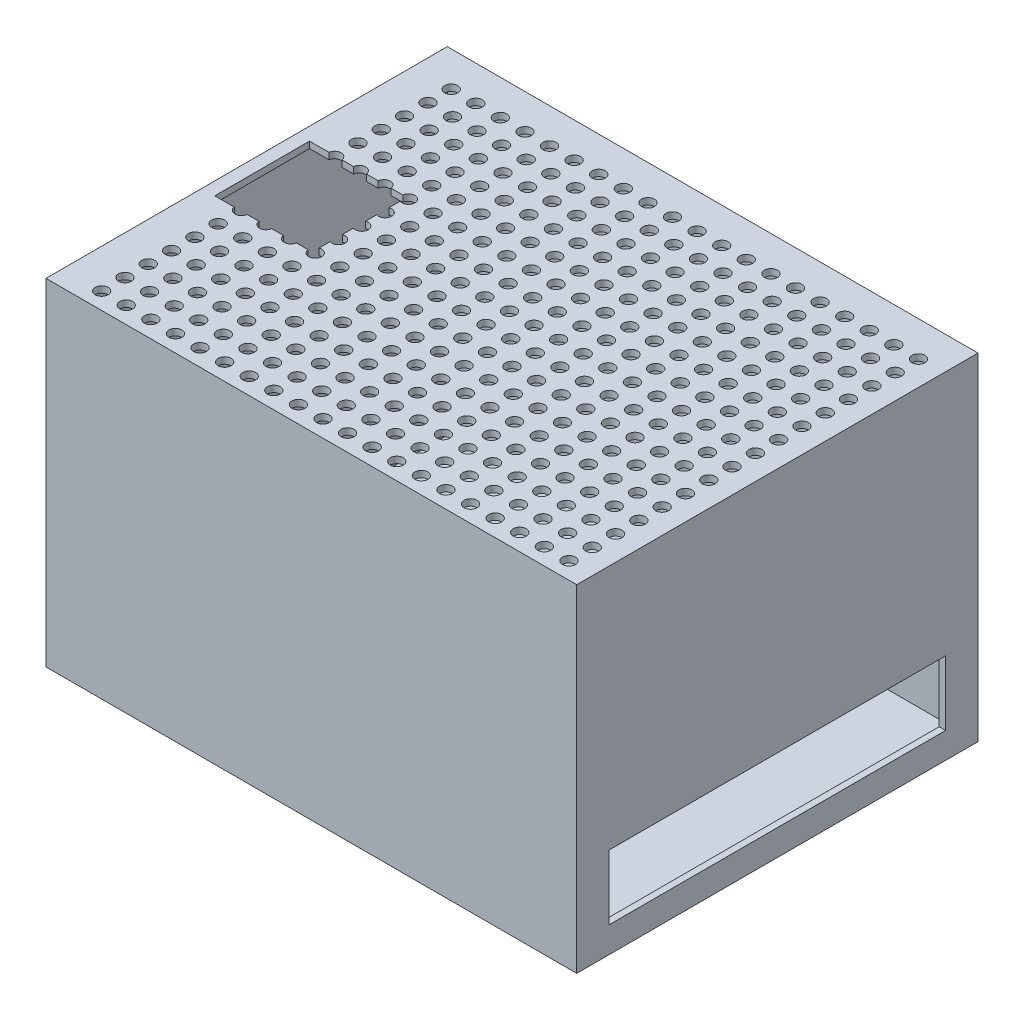
from build123d import *

# Parameters (mm, degrees)
SKETCH1_W           = 410
SKETCH1_H           = 260
SKETCH1_W_2         = 400
SKETCH1_H_2         = 250
BOSS_EXTRUDE1_DEPTH = 300
SKETCH2_W           = 410
SKETCH2_H           = 260
BOSS_EXTRUDE2_DEPTH = 5
SKETCH3_W           = 410
SKETCH3_H           = 260
BOSS_EXTRUDE3_DEPTH = 5
SKETCH4_R           = 5
CUT_EXTRUDE1_DEPTH  = 10
LPATTERN1_COUNT     = 16
LPATTERN1_PITCH     = 18
SKETCH5_W           = 75.209999999
SKETCH5_H           = 73.21
CUT_EXTRUDE2_DEPTH  = 10
SKETCH8_W           = 260
SKETCH8_H           = 50
CUT_EXTRUDE3_DEPTH  = 10


with BuildPart() as part:
    # Sketch1 → Boss-Extrude1 (new body)
    with BuildSketch(Plane.XY):
        with Locations((200, 125)):
            Rectangle(SKETCH1_W, SKETCH1_H)
        with Locations((200, 125)):
            Rectangle(SKETCH1_W_2, SKETCH1_H_2, mode=Mode.SUBTRACT)
    extrude(amount=BOSS_EXTRUDE1_DEPTH)

    # Sketch2 → Boss-Extrude2 (add)
    with BuildSketch(Plane.XY.offset(300)):
        with Locations((200, 125)):
            Rectangle(SKETCH2_W, SKETCH2_H)
    extrude(amount=BOSS_EXTRUDE2_DEPTH)

    # Sketch3 → Boss-Extrude3 (add)
    with BuildSketch(Plane(origin=(0, 0, 0), x_dir=(-1, 0, 0), z_dir=(0, 0, -1))):
        with Locations((-200, 125)):
            Rectangle(SKETCH3_W, SKETCH3_H)
    extrude(amount=BOSS_EXTRUDE3_DEPTH)

    # Sketch4 → Cut-Extrude1 (cut)
    with BuildSketch(Plane(origin=(0, 255, 0), x_dir=(1, 0, 0), z_dir=(0, 1, 0))):
        with Locations((25, -22)):
            Circle(SKETCH4_R)
        with Locations((44, -22)):
            Circle(SKETCH4_R)
        with Locations((63, -22)):
            Circle(SKETCH4_R)
        with Locations((82, -22)):
            Circle(SKETCH4_R)
        with Locations((101, -22)):
            Circle(SKETCH4_R)
        with Locations((120, -22)):
            Circle(SKETCH4_R)
        with Locations((139, -22)):
            Circle(SKETCH4_R)
        with Locations((158, -22)):
            Circle(SKETCH4_R)
        with Locations((177, -22)):
            Circle(SKETCH4_R)
        with Locations((196, -22)):
            Circle(SKETCH4_R)
        with Locations((215, -22)):
            Circle(SKETCH4_R)
        with Locations((234, -22)):
            Circle(SKETCH4_R)
        with Locations((253, -22)):
            Circle(SKETCH4_R)
        with Locations((272, -22)):
            Circle(SKETCH4_R)
        with Locations((291, -22)):
            Circle(SKETCH4_R)
        with Locations((310, -22)):
            Circle(SKETCH4_R)
        with Locations((329, -22)):
            Circle(SKETCH4_R)
        with Locations((348, -22)):
            Circle(SKETCH4_R)
        with Locations((367, -22)):
            Circle(SKETCH4_R)
        with Locations((386, -22)):
            Circle(SKETCH4_R)
    cut_extrude1 = extrude(amount=-CUT_EXTRUDE1_DEPTH, mode=Mode.SUBTRACT)

    # LPattern1: Cut-Extrude1 ×16
    with Locations(*[(0, 0, i * LPATTERN1_PITCH) for i in range(1, LPATTERN1_COUNT)]):
        add(cut_extrude1, mode=Mode.SUBTRACT)

    # Sketch5 → Cut-Extrude2 (cut)
    with BuildSketch(Plane(origin=(0, 255, 0), x_dir=(1, 0, 0), z_dir=(0, 1, 0))):
        with Locations((42.605, -148)):
            Rectangle(SKETCH5_W, SKETCH5_H)
    extrude(amount=-CUT_EXTRUDE2_DEPTH, mode=Mode.SUBTRACT)

    # Sketch8 → Cut-Extrude3 (cut)
    with BuildSketch(Plane(origin=(405, 0, 0), x_dir=(0, 0, -1), z_dir=(1, 0, 0))):
        with Locations((-150, 40)):
            Rectangle(SKETCH8_W, SKETCH8_H)
    extrude(amount=-CUT_EXTRUDE3_DEPTH, mode=Mode.SUBTRACT)


solid = part.part
